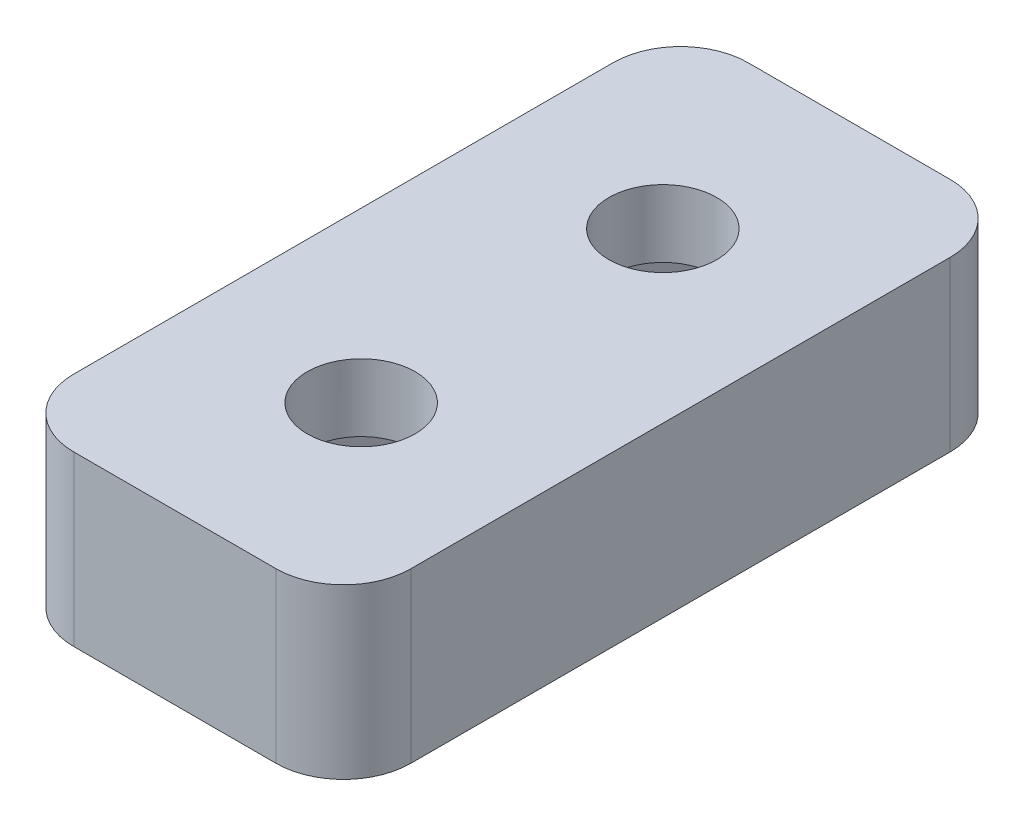
from build123d import *

# Parameters (mm, degrees)
CROQUIS1_W              = 10
CROQUIS1_H              = 20
CROQUIS1_R              = 1.6
SALIENTE_EXTRUIR1_DEPTH = 5
CORTAR_EXTRUIR1_DEPTH   = 3
REDONDEO1_R             = 2


with BuildPart() as part:
    # Croquis1 → Saliente-Extruir1 (new body)
    with BuildSketch(Plane(origin=(0, 0, 0), x_dir=(1, 0, 0), z_dir=(0, 1, 0))):
        Rectangle(CROQUIS1_W, CROQUIS1_H)
        with Locations((0, 4.474482181)):
            Circle(CROQUIS1_R, mode=Mode.SUBTRACT)
        with Locations((0, -4.474482181)):
            Circle(CROQUIS1_R, mode=Mode.SUBTRACT)
    extrude(amount=SALIENTE_EXTRUIR1_DEPTH)

    # Croquis2 → Cortar-Extruir1 (cut)
    with BuildSketch(Plane.XZ):
        Polygon((3.233161507, 4.474482181), (1.616580754, 7.274482181), (-1.616580754, 7.274482181), (-3.233161507, 4.474482181), (-1.616580754, 1.674482181), (1.616580754, 1.674482181), align=None)
        Polygon((1.616580754, -1.674482181), (3.233161507, -4.474482181), (1.616580754, -7.274482181), (-1.616580754, -7.274482181), (-3.233161507, -4.474482181), (-1.616580754, -1.674482181), align=None)
    extrude(amount=-CORTAR_EXTRUIR1_DEPTH, mode=Mode.SUBTRACT)

    # Redondeo1
    redondeo1_edges = [part.edges().sort_by_distance(p)[0] for p in [
        (5, 2.5, 10),
        (-5, 2.5, 10),
        (-5, 2.5, -10),
        (5, 2.5, -10),
    ]]
    fillet(redondeo1_edges, radius=REDONDEO1_R)


solid = part.part
